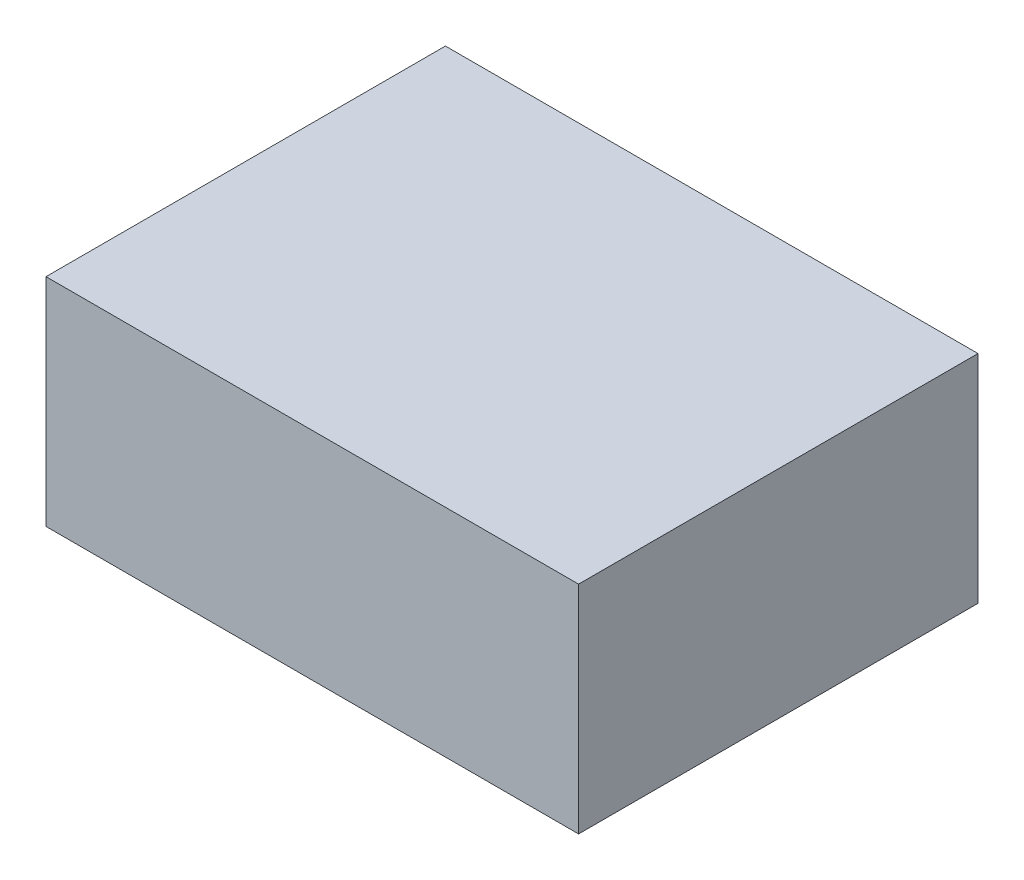
from build123d import *

# Parameters (mm, degrees)
SKETCH1_W           = 406.4
SKETCH1_H           = 304.8
BOSS_EXTRUDE1_DEPTH = 165.1


with BuildPart() as part:
    # Sketch1 → Boss-Extrude1 (new body)
    with BuildSketch(Plane(origin=(0, 0, 0), x_dir=(1, 0, 0), z_dir=(0, 1, 0))):
        Rectangle(SKETCH1_W, SKETCH1_H)
    extrude(amount=BOSS_EXTRUDE1_DEPTH)


solid = part.part
